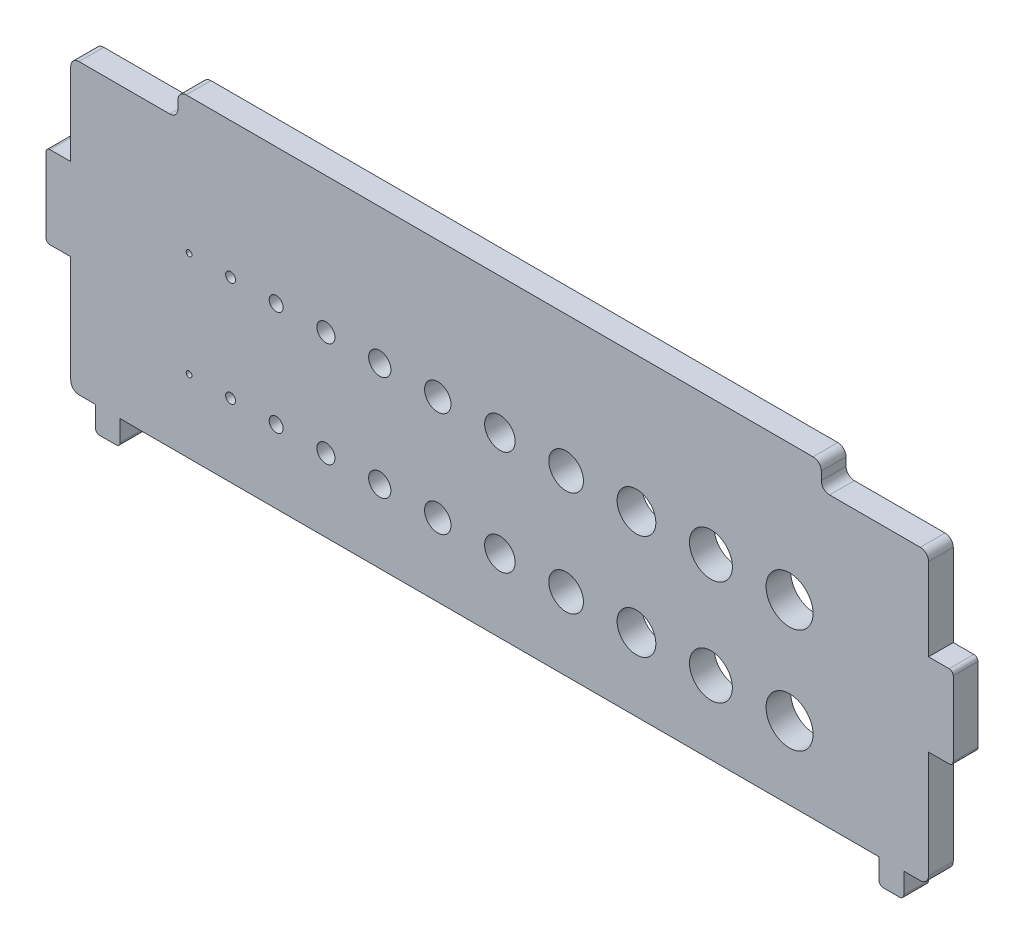
from build123d import *

# Parameters (mm, degrees)
SKETCH_1_R      = 0.35
SKETCH_1_R_2    = 0.6
SKETCH_1_R_3    = 0.85
SKETCH_1_R_4    = 1.1
SKETCH_1_R_5    = 1.35
SKETCH_1_R_6    = 1.6
SKETCH_1_R_7    = 1.85
SKETCH_1_R_8    = 2.1
SKETCH_1_R_9    = 2.35
SKETCH_1_R_10   = 2.6
SKETCH_1_R_11   = 2.85
SKETCH_1_W      = 3
SKETCH_1_H      = 10
EXTRUDE_1_DEPTH = 3
FILLET_1_R      = 0.5
FILLET_2_R      = 1


with BuildPart() as part:
    # Эскиз1 → Бобышка-Вытянуть1 (new body)
    with BuildSketch(Plane.XY):
        Polygon((39, 19), (-39, 19), (-39, 16), (-52, 16), (-52, 5), (-52, -5), (-52, -19), (-49, -19), (-49, -22), (-46, -22), (-46, -19), (0, -19), (46, -19), (46, -22), (49, -22), (49, -19), (52, -19), (52, -5), (52, 5), (52, 16), (39, 16), align=None)
        with Locations((-37.65, -10.15)):
            Circle(SKETCH_1_R, mode=Mode.SUBTRACT)
        with Locations((-32.62, -10.15)):
            Circle(SKETCH_1_R_2, mode=Mode.SUBTRACT)
        with Locations((-27.09, -10.15)):
            Circle(SKETCH_1_R_3, mode=Mode.SUBTRACT)
        with Locations((-21.06, -10.15)):
            Circle(SKETCH_1_R_4, mode=Mode.SUBTRACT)
        with Locations((-14.53, -10.15)):
            Circle(SKETCH_1_R_5, mode=Mode.SUBTRACT)
        with Locations((-7.5, -10.15)):
            Circle(SKETCH_1_R_6, mode=Mode.SUBTRACT)
        with Locations((0.03, -10.15)):
            Circle(SKETCH_1_R_7, mode=Mode.SUBTRACT)
        with Locations((8.06, -10.15)):
            Circle(SKETCH_1_R_8, mode=Mode.SUBTRACT)
        with Locations((16.59, -10.15)):
            Circle(SKETCH_1_R_9, mode=Mode.SUBTRACT)
        with Locations((25.62, -10.15)):
            Circle(SKETCH_1_R_10, mode=Mode.SUBTRACT)
        with Locations((35.15, -10.15)):
            Circle(SKETCH_1_R_11, mode=Mode.SUBTRACT)
        with Locations((-37.65, 2.55)):
            Circle(SKETCH_1_R, mode=Mode.SUBTRACT)
        with Locations((-32.62, 2.55)):
            Circle(SKETCH_1_R_2, mode=Mode.SUBTRACT)
        with Locations((-27.09, 2.55)):
            Circle(SKETCH_1_R_3, mode=Mode.SUBTRACT)
        with Locations((-21.06, 2.55)):
            Circle(SKETCH_1_R_4, mode=Mode.SUBTRACT)
        with Locations((-14.53, 2.55)):
            Circle(SKETCH_1_R_5, mode=Mode.SUBTRACT)
        with Locations((-7.5, 2.55)):
            Circle(SKETCH_1_R_6, mode=Mode.SUBTRACT)
        with Locations((0.03, 2.55)):
            Circle(SKETCH_1_R_7, mode=Mode.SUBTRACT)
        with Locations((8.06, 2.55)):
            Circle(SKETCH_1_R_8, mode=Mode.SUBTRACT)
        with Locations((16.59, 2.55)):
            Circle(SKETCH_1_R_9, mode=Mode.SUBTRACT)
        with Locations((25.62, 2.55)):
            Circle(SKETCH_1_R_10, mode=Mode.SUBTRACT)
        with Locations((35.15, 2.55)):
            Circle(SKETCH_1_R_11, mode=Mode.SUBTRACT)
        with Locations((-53.5, 0)):
            Rectangle(SKETCH_1_W, SKETCH_1_H)
        with Locations((53.5, 0)):
            Rectangle(SKETCH_1_W, SKETCH_1_H)
    extrude(amount=EXTRUDE_1_DEPTH)

    # Скругление1
    fillet_1_edges = [part.edges().sort_by_distance(p)[0] for p in [
        (-55, -5, 1.5),
        (-55, 5, 1.5),
        (55, 5, 1.5),
        (55, -5, 1.5),
        (49, -22, 1.5),
        (46, -22, 1.5),
        (-46, -22, 1.5),
        (-49, -22, 1.5),
    ]]
    fillet(fillet_1_edges, radius=FILLET_1_R)

    # Скругление2
    fillet_2_edges = [part.edges().sort_by_distance(p)[0] for p in [
        (-52, -19, 1.5),
        (-52, 16, 1.5),
        (-39, 16, 1.5),
        (-39, 19, 1.5),
        (39, 19, 1.5),
        (39, 16, 1.5),
        (52, 16, 1.5),
        (52, -19, 1.5),
    ]]
    fillet(fillet_2_edges, radius=FILLET_2_R)


solid = part.part
